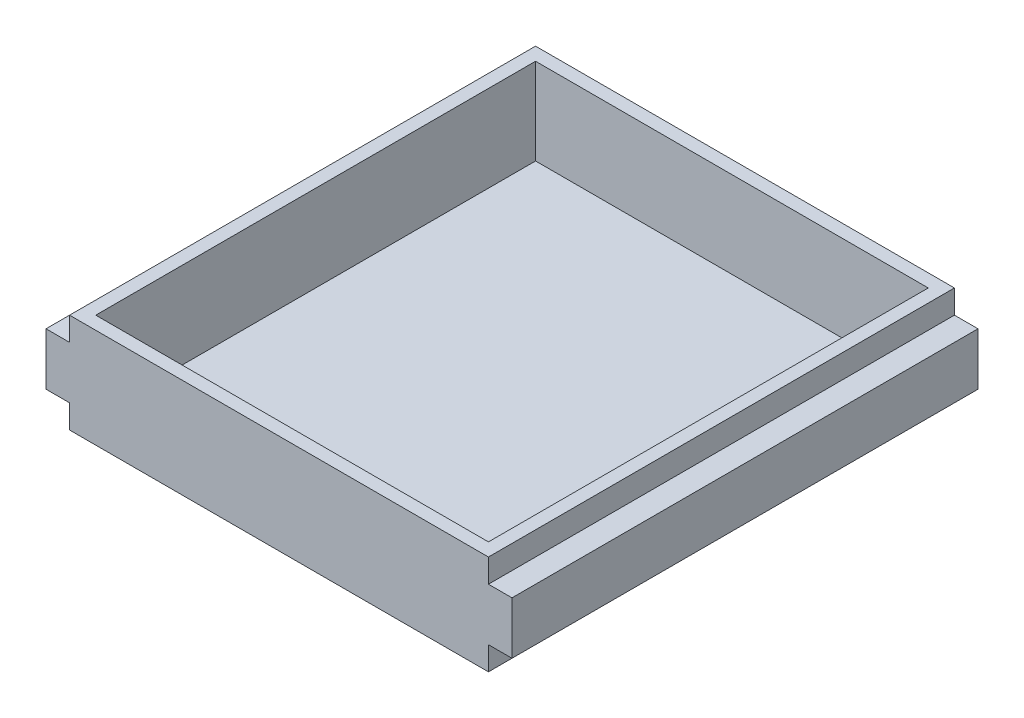
from build123d import *

# Parameters (mm, degrees)
BOSS_EXTRUDE1_DEPTH = 178
SKETCH2_W           = 150
SKETCH2_H           = 168
CUT_EXTRUDE1_DEPTH  = 33


with BuildPart() as part:
    # Sketch1 → Boss-Extrude1 (new body)
    with BuildSketch(Plane.XY):
        Polygon((169, -9), (9, -9), (9, 0), (0, 0), (0, 20), (9, 20), (9, 29), (169, 29), (169, 20), (178, 20), (178, 0), (169, 0), align=None)
    extrude(amount=-BOSS_EXTRUDE1_DEPTH)

    # Sketch2 → Cut-Extrude1 (cut)
    with BuildSketch(Plane(origin=(0, 29, 0), x_dir=(1, 0, 0), z_dir=(0, 1, 0))):
        with Locations((89, 89)):
            Rectangle(SKETCH2_W, SKETCH2_H)
    extrude(amount=-CUT_EXTRUDE1_DEPTH, mode=Mode.SUBTRACT)


solid = part.part
